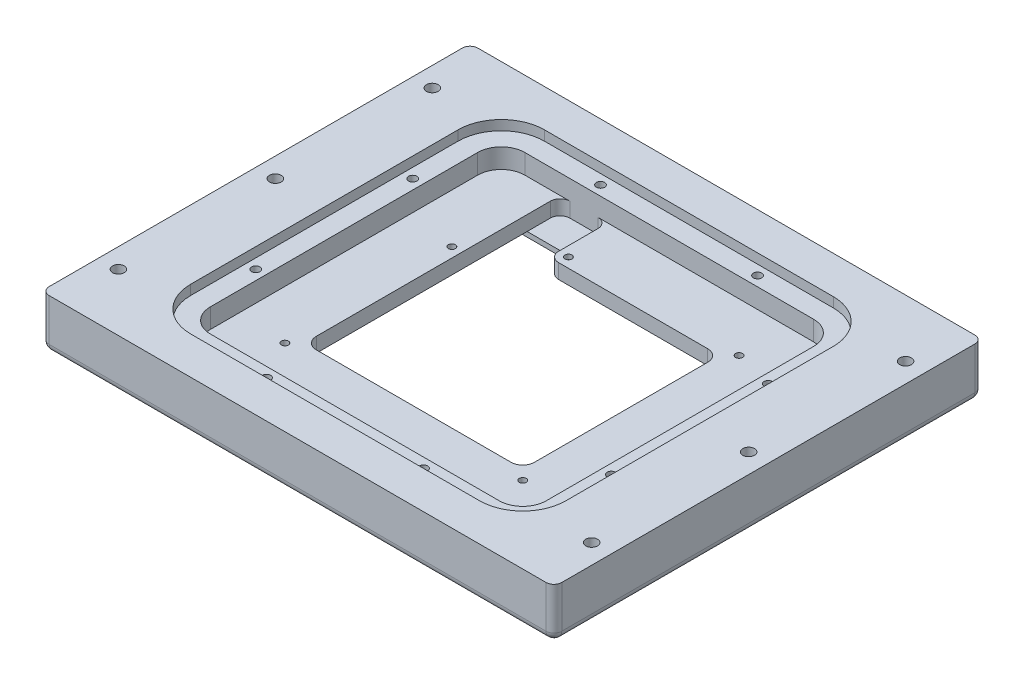
from build123d import *

# Parameters (mm, degrees)
SKETCH2_W                                      = 146.812
SKETCH2_H                                      = 139.8524
SKETCH2_W_2                                    = 83.312
SKETCH2_H_2                                    = 76.3524
SKETCH2_W_3                                    = 21.7424
SKETCH2_H_3                                    = 15.9766
BOSS_EXTRUDE1_DEPTH                            = 15.875
BOSS_EXTRUDE2_DEPTH                            = 9.525
CUT_EXTRUDE2_DEPTH                             = 3.175
M2_5X0_45_TAPPED_HOLE1_D                       = 2.05
M2_5X0_45_TAPPED_HOLE1_DEPTH                   = 6.35
M2_5X0_45_TAPPED_HOLE1_TIP                     = 0.615882135
CUT_EXTRUDE3_DEPTH                             = 6.35
CUT_EXTRUDE4_DEPTH                             = 1.6
SKETCH12_W                                     = 70.612
SKETCH12_H                                     = 63.6524
CUT_EXTRUDE5_DEPTH                             = 12.1
FILLET1_R                                      = 3.81
SKETCH13_W                                     = 146.812
SKETCH13_H                                     = 139.8524
CUT_EXTRUDE6_DEPTH                             = 1.5875
SKETCH14_W                                     = 15.3924
SKETCH14_H                                     = 22.86
CUT_EXTRUDE7_DEPTH                             = 4.75
FILLET3_R                                      = 3.175
SKETCH15_W                                     = 146.812
SKETCH15_H                                     = 139.8524
BOSS_EXTRUDE3_DEPTH                            = 3.175
F_6_32_TAPPED_HOLE1_AT_2_COUNT                 = 2
F_6_32_TAPPED_HOLE1_AT_2_PITCH                 = 108.1024
F_6_32_TAPPED_HOLE1_AT_3_COUNT                 = 2
F_6_32_TAPPED_HOLE1_AT_3_PITCH                 = 85.702359025
F_6_32_TAPPED_HOLE1_AT_4_COUNT                 = 2
F_6_32_TAPPED_HOLE1_AT_4_PITCH                 = 43.049882955
SKETCH19_R                                     = 2.7813
CUT_EXTRUDE8_DEPTH                             = 3.175
F_4_40_TAPPED_HOLE1_D                          = 2.2606
F_4_40_TAPPED_HOLE1_DEPTH                      = 7.62
F_4_40_TAPPED_HOLE1_TIP                        = 0.679152758
SKETCH22_W                                     = 146.812
SKETCH22_H                                     = 139.8524
CUT_EXTRUDE9_DEPTH                             = 1.524
SKETCH23_W                                     = 93.472
SKETCH23_H                                     = 6.604
SKETCH23_W_2                                   = 6.604
SKETCH23_H_2                                   = 86.5124
CUT_EXTRUDE10_DEPTH                            = 0.680085
SKETCH29_W                                     = 165.862
SKETCH29_H                                     = 158.9024
SKETCH29_W_2                                   = 146.812
SKETCH29_H_2                                   = 139.8524
BOSS_EXTRUDE4_DEPTH                            = 15.9385
SKETCH30_W                                     = 165.862
SKETCH30_H                                     = 158.9024
BOSS_EXTRUDE5_DEPTH                            = 0.27178
SKETCH34_W                                     = 165.862
SKETCH34_H                                     = 10.08634
CUT_EXTRUDE12_DEPTH                            = 17.21028
FILLET4_R                                      = 2.54
CBORE_FOR_6_SOCKET_HEAD_CAP_SCREW1_D           = 3.7973
CBORE_FOR_6_SOCKET_HEAD_CAP_SCREW1_CBORE_D     = 7.14502
CBORE_FOR_6_SOCKET_HEAD_CAP_SCREW1_CBORE_DEPTH = 3.5052


with BuildPart() as part:
    # Sketch2 → Boss-Extrude1 (new body)
    with BuildSketch(Plane(origin=(0, 0, 0), x_dir=(1, 0, 0), z_dir=(0, 1, 0))):
        Rectangle(SKETCH2_W, SKETCH2_H)
        Rectangle(SKETCH2_W_2, SKETCH2_H_2, mode=Mode.SUBTRACT)
        with Locations((-30.7848, 30.1879)):
            Rectangle(SKETCH2_W_3, SKETCH2_H_3)
    extrude(amount=BOSS_EXTRUDE1_DEPTH)

    # Sketch4 → Boss-Extrude2 (add)
    with BuildSketch(Plane(origin=(0, 0, 0), x_dir=(1, 0, 0), z_dir=(0, 1, 0))):
        Polygon((41.656, -38.1762), (41.656, 38.1762), (-19.9136, 38.1762), (-19.9136, 22.1996), (-41.656, 22.1996), (-41.656, -38.1762), align=None)
        Polygon((35.306, 31.8262), (-13.5636, 31.8262), (-13.5636, 15.8496), (-35.306, 15.8496), (-35.306, -31.8262), (35.306, -31.8262), align=None, mode=Mode.SUBTRACT)
    extrude(amount=BOSS_EXTRUDE2_DEPTH)

    # Sketch5 → Cut-Extrude2 (cut)
    with BuildSketch(Plane.XZ):
        with BuildLine():
            Line((46.736, -50.8762), (-46.736, -50.8762))
            ThreePointArc((-46.736, -50.8762), (-52.124153673, -48.644353673), (-54.356, -43.2562))
            Line((-54.356, -43.2562), (-54.356, 43.2562))
            ThreePointArc((-54.356, 43.2562), (-52.124153673, 48.644353673), (-46.736, 50.8762))
            Line((-46.736, 50.8762), (46.736, 50.8762))
            ThreePointArc((46.736, 50.8762), (52.124153673, 48.644353673), (54.356, 43.2562))
            Line((54.356, 43.2562), (54.356, -43.2562))
            ThreePointArc((54.356, -43.2562), (52.124153673, -48.644353673), (46.736, -50.8762))
        make_face()
    extrude(amount=-CUT_EXTRUDE2_DEPTH, mode=Mode.SUBTRACT)

    # M2.5x0.45 Tapped Hole1
    with Locations(Plane(origin=(0, 3.175, 0), x_dir=(-1, 0, 0), z_dir=(0, -1, 0))):
        with Locations((38.481, -35.0012), (-38.481, -35.0012), (38.481, 19.0246), (16.7386, 35.0012), (-38.481, 35.0012)):
            Hole(M2_5X0_45_TAPPED_HOLE1_D / 2, depth=M2_5X0_45_TAPPED_HOLE1_DEPTH)
            with Locations((0, 0, -(M2_5X0_45_TAPPED_HOLE1_DEPTH + M2_5X0_45_TAPPED_HOLE1_TIP / 2))):  # 118° drill point
                Cone(0, M2_5X0_45_TAPPED_HOLE1_D / 2, M2_5X0_45_TAPPED_HOLE1_TIP, mode=Mode.SUBTRACT)

    # Sketch10 → Cut-Extrude3 (cut)
    with BuildSketch(Plane(origin=(0, 15.875, 0), x_dir=(1, 0, 0), z_dir=(0, 1, 0))):
        with BuildLine():
            Line((54.356, -43.2562), (54.356, 43.2562))
            ThreePointArc((54.356, 43.2562), (52.124153673, 48.644353673), (46.736, 50.8762))
            Line((46.736, 50.8762), (-46.736, 50.8762))
            ThreePointArc((-46.736, 50.8762), (-52.124153673, 48.644353673), (-54.356, 43.2562))
            Line((-54.356, 43.2562), (-54.356, -43.2562))
            ThreePointArc((-54.356, -43.2562), (-52.124153673, -48.644353673), (-46.736, -50.8762))
            Line((-46.736, -50.8762), (46.736, -50.8762))
            ThreePointArc((46.736, -50.8762), (52.124153673, -48.644353673), (54.356, -43.2562))
        make_face()
    extrude(amount=-CUT_EXTRUDE3_DEPTH, mode=Mode.SUBTRACT)

    # Sketch11 → Cut-Extrude4 (cut)
    with BuildSketch(Plane.XZ.offset(-3.175)):
        with BuildLine():
            Line((40.513, 40.2082), (-40.513, 40.2082))
            ThreePointArc((-40.513, 40.2082), (-42.75806403, 39.27826403), (-43.688, 37.0332))
            Line((-43.688, 37.0332), (-43.688, -37.0332))
            ThreePointArc((-43.688, -37.0332), (-42.75806403, -39.27826403), (-40.513, -40.2082))
            Line((-40.513, -40.2082), (40.513, -40.2082))
            ThreePointArc((40.513, -40.2082), (42.75806403, -39.27826403), (43.688, -37.0332))
            Line((43.688, -37.0332), (43.688, 37.0332))
            ThreePointArc((43.688, 37.0332), (42.75806403, 39.27826403), (40.513, 40.2082))
        make_face()
    extrude(amount=-CUT_EXTRUDE4_DEPTH, mode=Mode.SUBTRACT)

    # Sketch12 → Cut-Extrude5 (cut, through all)
    with BuildSketch(Plane.XZ.offset(-4.775)):
        Rectangle(SKETCH12_W, SKETCH12_H)
    extrude(amount=-CUT_EXTRUDE5_DEPTH, mode=Mode.SUBTRACT)

    # Fillet1
    fillet1_edges = [part.edges().sort_by_distance(p)[0] for p in [
        (-35.306, 7.15, -31.8262),
        (35.306, 7.15, -31.8262),
        (-35.306, 7.15, 31.8262),
        (35.306, 7.15, 31.8262),
    ]]
    fillet(fillet1_edges, radius=FILLET1_R)

    # Sketch13 → Cut-Extrude6 (cut)
    with BuildSketch(Plane.XZ):
        Rectangle(SKETCH13_W, SKETCH13_H)
        with BuildLine():
            Line((54.356, -43.2562), (54.356, 43.2562))
            ThreePointArc((54.356, 43.2562), (52.124153673, 48.644353673), (46.736, 50.8762))
            Line((46.736, 50.8762), (-46.736, 50.8762))
            ThreePointArc((-46.736, 50.8762), (-52.124153673, 48.644353673), (-54.356, 43.2562))
            Line((-54.356, 43.2562), (-54.356, -43.2562))
            ThreePointArc((-54.356, -43.2562), (-52.124153673, -48.644353673), (-46.736, -50.8762))
            Line((-46.736, -50.8762), (46.736, -50.8762))
            ThreePointArc((46.736, -50.8762), (52.124153673, -48.644353673), (54.356, -43.2562))
        make_face(mode=Mode.SUBTRACT)
    extrude(amount=-CUT_EXTRUDE6_DEPTH, mode=Mode.SUBTRACT)

    # Sketch14 → Cut-Extrude7 (cut)
    with BuildSketch(Plane(origin=(0, 9.525, 0), x_dir=(1, 0, 0), z_dir=(0, 1, 0))):
        with Locations((-27.6098, 39.4462)):
            Rectangle(SKETCH14_W, SKETCH14_H)
    extrude(amount=-CUT_EXTRUDE7_DEPTH, mode=Mode.SUBTRACT)

    # Fillet3
    fillet3_edges = [part.edges().sort_by_distance(p)[0] for p in [
        (-19.9136, 7.15, -31.8262),
        (-19.9136, 7.15, -50.8762),
        (-35.306, 7.15, -50.8762),
    ]]
    fillet(fillet3_edges, radius=FILLET3_R)

    # Sketch15 → Boss-Extrude3 (add)
    with BuildSketch(Plane(origin=(0, 15.875, 0), x_dir=(1, 0, 0), z_dir=(0, 1, 0))):
        Rectangle(SKETCH15_W, SKETCH15_H)
        with BuildLine():
            ThreePointArc((46.736, -57.2262), (56.614281733, -53.134481733), (60.706, -43.2562))
            Line((60.706, -43.2562), (60.706, 43.2562))
            ThreePointArc((60.706, 43.2562), (56.614281733, 53.134481733), (46.736, 57.2262))
            Line((46.736, 57.2262), (-46.736, 57.2262))
            ThreePointArc((-46.736, 57.2262), (-56.614281733, 53.134481733), (-60.706, 43.2562))
            Line((-60.706, 43.2562), (-60.706, -43.2562))
            ThreePointArc((-60.706, -43.2562), (-56.614281733, -53.134481733), (-46.736, -57.2262))
            Line((-46.736, -57.2262), (46.736, -57.2262))
        make_face(mode=Mode.SUBTRACT)
    extrude(amount=BOSS_EXTRUDE3_DEPTH)

    # Sketch18 → #6-32 Tapped Hole1 (revolve, cut)
    with BuildSketch(Plane(origin=(-25.4, 15.875, 54.0512), x_dir=(0, 0, 1), z_dir=(1, 0, 0))):
        Polygon((0, 0), (0, 10.33769403), (1.35255, 9.525), (1.35255, 0), align=None)
    f_6_32_tapped_hole1 = revolve(axis=Axis((-25.4, 22.225, 54.0512), (0, -1, 0)), mode=Mode.SUBTRACT)

    # #6-32 Tapped Hole1 at 2: #6-32 Tapped Hole1 ×2
    with Locations(*[(0, 0, -i * F_6_32_TAPPED_HOLE1_AT_2_PITCH) for i in range(1, F_6_32_TAPPED_HOLE1_AT_2_COUNT)]):
        add(f_6_32_tapped_hole1, mode=Mode.SUBTRACT)

    # #6-32 Tapped Hole1 at 3: #6-32 Tapped Hole1 ×2
    with Locations(*[Vector(-0.374913834, 0, -0.927059662) * (i * F_6_32_TAPPED_HOLE1_AT_3_PITCH) for i in range(1, F_6_32_TAPPED_HOLE1_AT_3_COUNT)]):
        add(f_6_32_tapped_hole1, mode=Mode.SUBTRACT)

    # #6-32 Tapped Hole1 at 4: #6-32 Tapped Hole1 ×2
    with Locations(*[Vector(-0.746366721, 0, -0.665534911) * (i * F_6_32_TAPPED_HOLE1_AT_4_PITCH) for i in range(1, F_6_32_TAPPED_HOLE1_AT_4_COUNT)]):
        add(f_6_32_tapped_hole1, mode=Mode.SUBTRACT)

    # Mirror1: #6-32 Tapped Hole1 across plane
    add(f_6_32_tapped_hole1.mirror(Plane(origin=(0, 0, 0), x_dir=(0, 0, 1), z_dir=(1, 0, 0))), mode=Mode.SUBTRACT)

    # Mirror1 copy 1 sketch → Mirror1 copy 1 (revolve, cut)
    with BuildSketch(Plane(origin=(25.4, 15.875, -54.0512), x_dir=(0, 0, 1), z_dir=(-1, 0, 0))):
        Polygon((0, 0), (0, -10.33769403), (1.35255, -9.525), (1.35255, 0), align=None)
    revolve(axis=Axis((25.4, 22.225, -54.0512), (0, 1, 0)), mode=Mode.SUBTRACT)

    # Mirror1 copy 2 sketch → Mirror1 copy 2 (revolve, cut)
    with BuildSketch(Plane(origin=(57.531, 15.875, -25.4), x_dir=(0, 0, 1), z_dir=(-1, 0, 0))):
        Polygon((0, 0), (0, -10.33769403), (1.35255, -9.525), (1.35255, 0), align=None)
    revolve(axis=Axis((57.531, 22.225, -25.4), (0, 1, 0)), mode=Mode.SUBTRACT)

    # Mirror1 copy 3 sketch → Mirror1 copy 3 (revolve, cut)
    with BuildSketch(Plane(origin=(57.531, 15.875, 25.4), x_dir=(0, 0, 1), z_dir=(-1, 0, 0))):
        Polygon((0, 0), (0, -10.33769403), (1.35255, -9.525), (1.35255, 0), align=None)
    revolve(axis=Axis((57.531, 22.225, 25.4), (0, 1, 0)), mode=Mode.SUBTRACT)

    # Sketch19 → Cut-Extrude8 (cut)
    with BuildSketch(Plane.XZ.offset(-4.775)):
        with Locations((38.481, 35.0012)):
            Circle(SKETCH19_R)
        with Locations((38.481, -35.0012)):
            Circle(SKETCH19_R)
        with Locations((-38.481, 35.0012)):
            Circle(SKETCH19_R)
        with Locations((-38.481, -19.0246)):
            Circle(SKETCH19_R)
        with Locations((-16.7386, -35.0012)):
            Circle(SKETCH19_R)
    extrude(amount=-CUT_EXTRUDE8_DEPTH, mode=Mode.SUBTRACT)

    # #4-40 Tapped Hole1
    with Locations(Plane(origin=(0, 9.525, 0), x_dir=(1, 0, 0), z_dir=(0, 1, 0))):
        with Locations((-38.481, 19.0246), (-16.7386, 35.0012), (38.481, 35.0012), (38.481, -35.0012), (-38.481, -35.0012)):
            Hole(F_4_40_TAPPED_HOLE1_D / 2, depth=F_4_40_TAPPED_HOLE1_DEPTH)
            with Locations((0, 0, -(F_4_40_TAPPED_HOLE1_DEPTH + F_4_40_TAPPED_HOLE1_TIP / 2))):  # 118° drill point
                Cone(0, F_4_40_TAPPED_HOLE1_D / 2, F_4_40_TAPPED_HOLE1_TIP, mode=Mode.SUBTRACT)

    # Sketch22 → Cut-Extrude9 (cut)
    with BuildSketch(Plane.XZ.offset(-1.5875)):
        Rectangle(SKETCH22_W, SKETCH22_H)
    extrude(amount=-CUT_EXTRUDE9_DEPTH, mode=Mode.SUBTRACT)

    # Sketch23 → Cut-Extrude10 (cut)
    with BuildSketch(Plane.XZ.offset(-3.175)):
        with BuildLine():
            Line((-54.356, 43.2562), (-47.752, 43.2562))
            ThreePointArc((-47.752, 43.2562), (-47.45442049, 43.97462049), (-46.736, 44.2722))
            Line((-46.736, 44.2722), (-46.736, 50.8762))
            ThreePointArc((-46.736, 50.8762), (-52.124153673, 48.644353673), (-54.356, 43.2562))
        make_face()
        with Locations((0, 47.5742)):
            Rectangle(SKETCH23_W, SKETCH23_H)
        with Locations((-51.054, 0)):
            Rectangle(SKETCH23_W_2, SKETCH23_H_2)
        with BuildLine():
            Line((46.736, 50.8762), (46.736, 44.2722))
            ThreePointArc((46.736, 44.2722), (47.442019638, 43.962219638), (47.752, 43.2562))
            Line((47.752, 43.2562), (54.356, 43.2562))
            ThreePointArc((54.356, 43.2562), (52.124153673, 48.644353673), (46.736, 50.8762))
        make_face()
        with BuildLine():
            Line((54.356, 43.2562), (47.752, 43.2562))
            ThreePointArc((47.752, 43.2562), (47.752937434, 43.211597678), (47.752, 43.166995356))
            Line((47.752, 43.166995356), (47.752, -43.2562))
            Line((47.752, -43.2562), (54.356, -43.2562))
            Line((54.356, -43.2562), (54.356, 43.2562))
        make_face()
        with BuildLine():
            Line((54.356, -43.2562), (47.752, -43.2562))
            ThreePointArc((47.752, -43.2562), (47.45442049, -43.97462049), (46.736, -44.2722))
            Line((46.736, -44.2722), (46.736, -50.8762))
            ThreePointArc((46.736, -50.8762), (52.124153673, -48.644353673), (54.356, -43.2562))
        make_face()
        with Locations((0, -47.5742)):
            Rectangle(SKETCH23_W, SKETCH23_H)
        with BuildLine():
            Line((-46.736, -50.8762), (-46.736, -44.2722))
            ThreePointArc((-46.736, -44.2722), (-47.45442049, -43.97462049), (-47.752, -43.2562))
            Line((-47.752, -43.2562), (-54.356, -43.2562))
            ThreePointArc((-54.356, -43.2562), (-52.124153673, -48.644353673), (-46.736, -50.8762))
        make_face()
    extrude(amount=-CUT_EXTRUDE10_DEPTH, mode=Mode.SUBTRACT)

    # Sketch29 → Boss-Extrude4 (add)
    with BuildSketch(Plane(origin=(0, 19.05, 0), x_dir=(1, 0, 0), z_dir=(0, 1, 0))):
        Rectangle(SKETCH29_W, SKETCH29_H)
        Rectangle(SKETCH29_W_2, SKETCH29_H_2, mode=Mode.SUBTRACT)
    extrude(amount=-BOSS_EXTRUDE4_DEPTH)

    # Sketch30 → Boss-Extrude5 (add)
    with BuildSketch(Plane.XZ.offset(-3.1115)):
        Rectangle(SKETCH30_W, SKETCH30_H)
        with BuildLine():
            Line((-46.736, 50.8762), (46.736, 50.8762))
            ThreePointArc((46.736, 50.8762), (52.124153673, 48.644353673), (54.356, 43.2562))
            Line((54.356, 43.2562), (54.356, -43.2562))
            ThreePointArc((54.356, -43.2562), (52.124153673, -48.644353673), (46.736, -50.8762))
            Line((46.736, -50.8762), (-46.736, -50.8762))
            ThreePointArc((-46.736, -50.8762), (-52.124153673, -48.644353673), (-54.356, -43.2562))
            Line((-54.356, -43.2562), (-54.356, 43.2562))
            ThreePointArc((-54.356, 43.2562), (-52.124153673, 48.644353673), (-46.736, 50.8762))
        make_face(mode=Mode.SUBTRACT)
    extrude(amount=BOSS_EXTRUDE5_DEPTH)

    # Sketch34 → Cut-Extrude12 (cut, through all)
    with BuildSketch(Plane(origin=(0, 19.05, 0), x_dir=(1, 0, 0), z_dir=(0, 1, 0))):
        with Locations((0, -74.40803)):
            Rectangle(SKETCH34_W, SKETCH34_H)
        with Locations((0, 74.40803)):
            Rectangle(SKETCH34_W, SKETCH34_H)
    extrude(amount=-CUT_EXTRUDE12_DEPTH, mode=Mode.SUBTRACT)

    # Fillet4
    fillet4_edges = [part.edges().sort_by_distance(p)[0] for p in [
        (-82.931, 2.83972, 0),
        (82.931, 2.83972, 0),
        (0, 2.83972, 69.36486),
        (-82.931, 10.94486, 69.36486),
        (82.931, 10.94486, 69.36486),
        (0, 2.83972, -69.36486),
        (82.931, 10.94486, -69.36486),
        (-82.931, 10.94486, -69.36486),
    ]]
    fillet(fillet4_edges, radius=FILLET4_R)

    # CBORE for #6 Socket Head Cap Screw1 (through all)
    with Locations(Plane(origin=(0, 2.83972, 0), x_dir=(-1, 0, 0), z_dir=(0, -1, 0))):
        with Locations((76.581, -50.8), (76.581, 0), (76.581, 50.8)):
            cbore_for_6_socket_head_cap_screw1 = CounterBoreHole(CBORE_FOR_6_SOCKET_HEAD_CAP_SCREW1_D / 2, CBORE_FOR_6_SOCKET_HEAD_CAP_SCREW1_CBORE_D / 2, CBORE_FOR_6_SOCKET_HEAD_CAP_SCREW1_CBORE_DEPTH)

    # Mirror3: CBORE for #6 Socket Head Cap Screw1 across plane
    add(cbore_for_6_socket_head_cap_screw1.mirror(Plane(origin=(0, 0, 0), x_dir=(0, 0, 1), z_dir=(1, 0, 0))), mode=Mode.SUBTRACT)


solid = part.part
